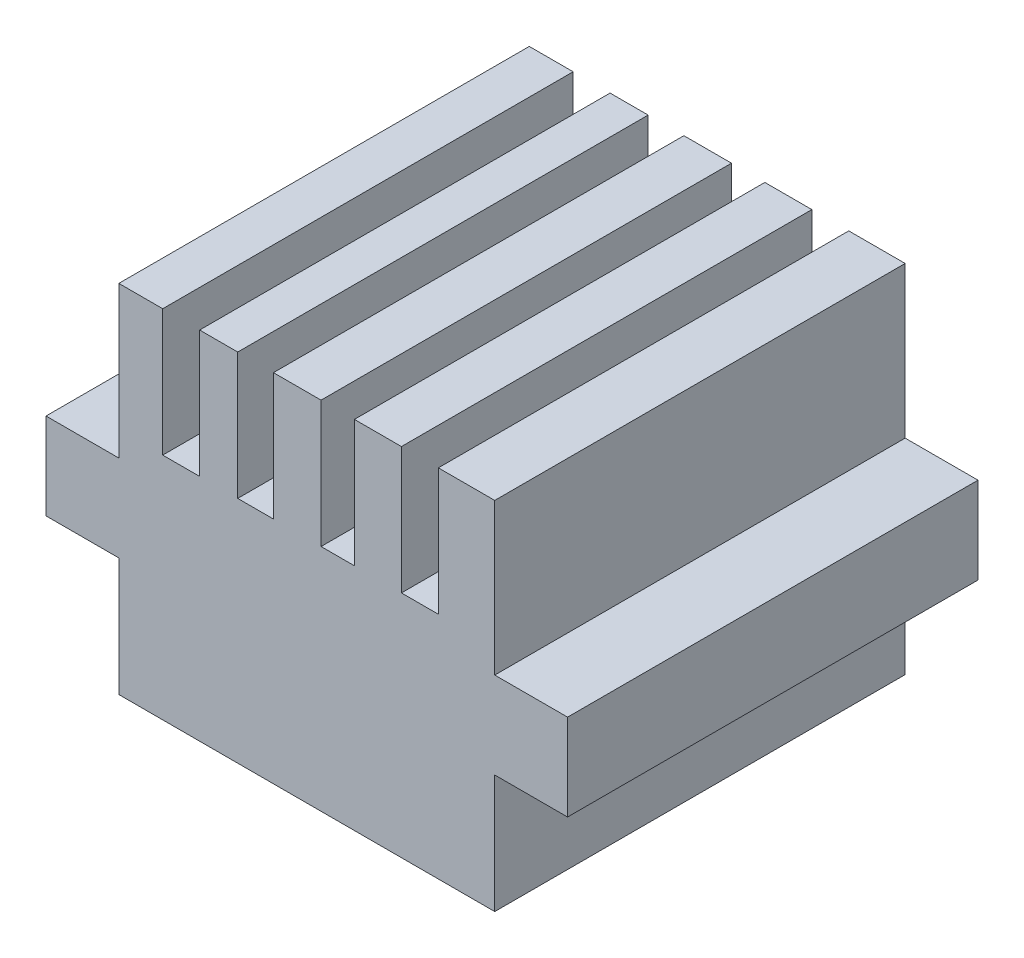
from build123d import *

# Parameters (mm, degrees)
CROQUIS1_W              = 28.85
CROQUIS1_H              = 31.5
SALIENTE_EXTRUIR1_DEPTH = 17.6
CROQUIS3_W              = 3.368460879
CROQUIS3_H              = 31.5
CROQUIS3_W_2            = 4.327912621
CROQUIS3_W_3            = 3.609366076
CROQUIS3_W_4            = 3.655054254
CROQUIS3_W_5            = 2.924043404
SALIENTE_EXTRUIR2_DEPTH = 9.73
CROQUIS4_W              = 31.5
CROQUIS4_H              = 6.64
SALIENTE_EXTRUIR3_DEPTH = 5.59
CROQUIS5_W              = 31.5
CROQUIS5_H              = 6.64
SALIENTE_EXTRUIR4_DEPTH = 5.59


with BuildPart() as part:
    # Croquis1 → Saliente-Extruir1 (new body)
    with BuildSketch(Plane(origin=(0, 0, 0), x_dir=(1, 0, 0), z_dir=(0, 1, 0))):
        with Locations((14.425, 15.75)):
            Rectangle(CROQUIS1_W, CROQUIS1_H)
    extrude(amount=SALIENTE_EXTRUIR1_DEPTH)

    # Croquis3 → Saliente-Extruir2 (add)
    with BuildSketch(Plane(origin=(0, 17.6, 0), x_dir=(1, 0, 0), z_dir=(0, 1, 0))):
        with Locations((1.68423044, 15.75)):
            Rectangle(CROQUIS3_W, CROQUIS3_H)
        with Locations((26.68604369, 15.75)):
            Rectangle(CROQUIS3_W_2, CROQUIS3_H)
        with Locations((19.884737293, 15.75)):
            Rectangle(CROQUIS3_W_3, CROQUIS3_H)
        with Locations((13.693989149, 15.75)):
            Rectangle(CROQUIS3_W_4, CROQUIS3_H)
        with Locations((7.663149629, 15.75)):
            Rectangle(CROQUIS3_W_5, CROQUIS3_H)
    extrude(amount=SALIENTE_EXTRUIR2_DEPTH)

    # Croquis4 → Saliente-Extruir3 (add)
    with BuildSketch(Plane.ZY):
        with Locations((-15.75, 12.4)):
            Rectangle(CROQUIS4_W, CROQUIS4_H)
    extrude(amount=SALIENTE_EXTRUIR3_DEPTH)

    # Croquis5 → Saliente-Extruir4 (add)
    with BuildSketch(Plane(origin=(28.85, 0, 0), x_dir=(0, 0, -1), z_dir=(1, 0, 0))):
        with Locations((15.75, 12.4)):
            Rectangle(CROQUIS5_W, CROQUIS5_H)
    extrude(amount=SALIENTE_EXTRUIR4_DEPTH)


solid = part.part
